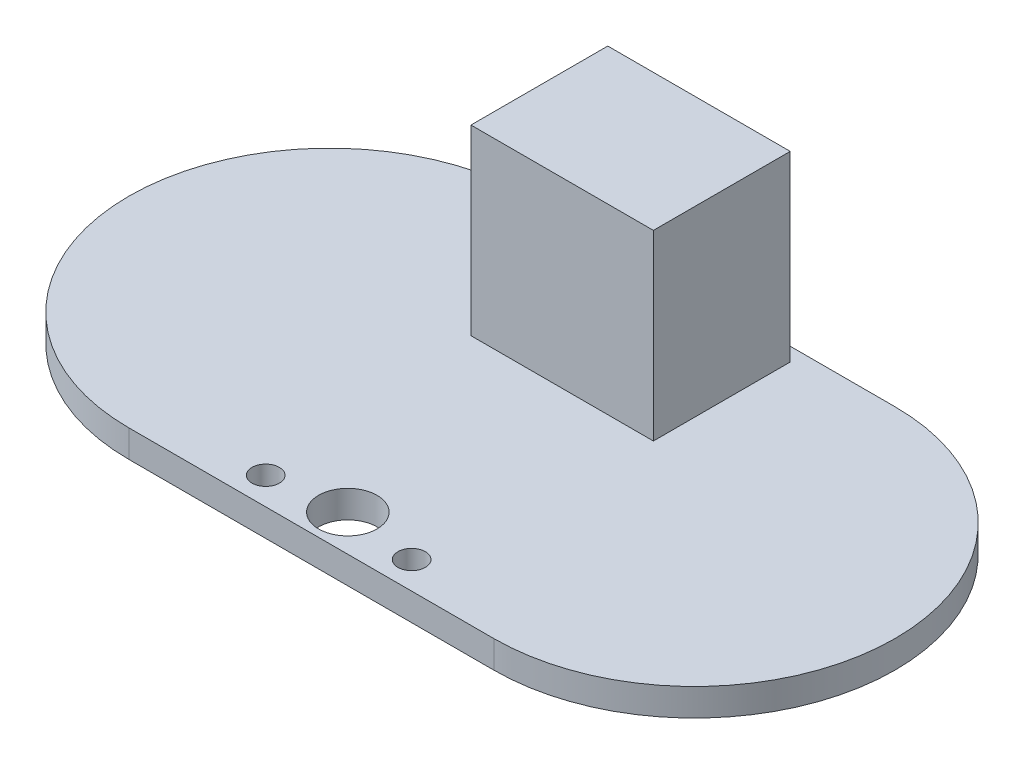
from build123d import *

# Parameters (mm, degrees)
BOSS_EXTRUDE1_DEPTH = 1.5
SKETCH2_W           = 10
SKETCH2_H           = 7.5
BOSS_EXTRUDE2_DEPTH = 10
SKETCH3_R           = 1.6
SKETCH3_R_2         = 0.75
CUT_EXTRUDE1_DEPTH  = 2.5


with BuildPart() as part:
    # Sketch1 → Boss-Extrude1 (new body)
    with BuildSketch(Plane(origin=(0, 0, 0), x_dir=(1, 0, 0), z_dir=(0, 1, 0))):
        with BuildLine():
            Line((-21, 0), (-10, 0))
            Line((-10, 0), (0, 0))
            Line((0, 0), (0, 11))
            Line((0, 11), (-10, 11))
            ThreePointArc((-10, 11), (-17.778174593, 7.778174593), (-21, 0))
        make_face()
        with BuildLine():
            Line((0, 0), (-10, 0))
            Line((-10, 0), (-21, 0))
            ThreePointArc((-21, 0), (-17.778174593, -7.778174593), (-10, -11))
            Line((-10, -11), (0, -11))
            Line((0, -11), (0, 0))
        make_face()
        with BuildLine():
            Line((10, 0), (0, 0))
            Line((0, 0), (0, -11))
            Line((0, -11), (10, -11))
            ThreePointArc((10, -11), (17.778174593, -7.778174593), (21, 0))
            Line((21, 0), (10, 0))
        make_face()
        with BuildLine():
            Line((0, 11), (0, 0))
            Line((0, 0), (10, 0))
            Line((10, 0), (21, 0))
            ThreePointArc((21, 0), (17.778174593, 7.778174593), (10, 11))
            Line((10, 11), (0, 11))
        make_face()
    extrude(amount=BOSS_EXTRUDE1_DEPTH)

    # Sketch2 → Boss-Extrude2 (add)
    with BuildSketch(Plane(origin=(0, 1.5, 0), x_dir=(1, 0, 0), z_dir=(0, 1, 0))):
        with Locations((0, 6.5)):
            Rectangle(SKETCH2_W, SKETCH2_H)
    extrude(amount=BOSS_EXTRUDE2_DEPTH)

    # Sketch3 → Cut-Extrude1 (cut, through all)
    with BuildSketch(Plane(origin=(0, 1.5, 0), x_dir=(1, 0, 0), z_dir=(0, 1, 0))):
        with Locations((0, -9)):
            Circle(SKETCH3_R)
        with Locations((-4, -9.5)):
            Circle(SKETCH3_R_2)
        with Locations((4, -9.5)):
            Circle(SKETCH3_R_2)
    extrude(amount=-CUT_EXTRUDE1_DEPTH, mode=Mode.SUBTRACT)


solid = part.part
